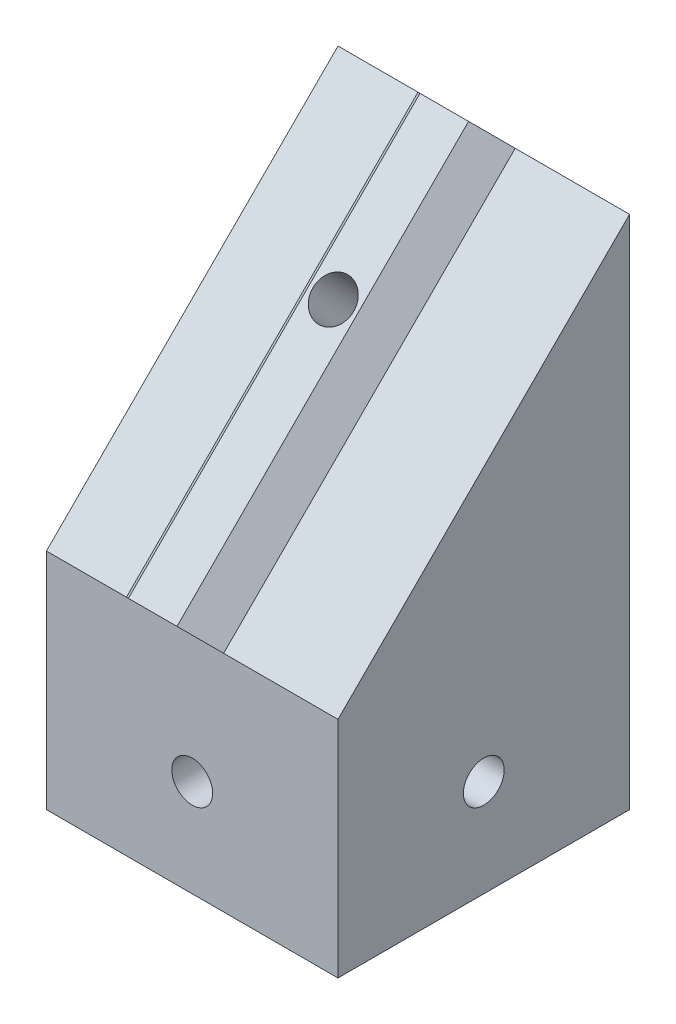
from build123d import *

# Parameters (mm, degrees)
SKETCH1_W           = 30
SKETCH1_H           = 30
SKETCH1_W_2         = 20
SKETCH1_H_2         = 20
BOSS_EXTRUDE1_DEPTH = 20
SKETCH2_W           = 4.711017494
SKETCH2_H           = 2
SKETCH2_W_2         = 2
SKETCH2_H_2         = 4.711017494
BOSS_EXTRUDE2_DEPTH = 20
SKETCH3_R           = 2.1
CUT_EXTRUDE1_DEPTH  = 31
SKETCH4_R           = 2.1
CUT_EXTRUDE2_DEPTH  = 31
BOSS_EXTRUDE3_DEPTH = 30
SKETCH8_W           = 4.711017494
SKETCH8_H           = 2.5
BOSS_EXTRUDE4_DEPTH = 42.42640687
SKETCH9_R           = 2.1
CUT_EXTRUDE3_DEPTH  = 44.261940705


with BuildPart() as part:
    # Sketch1 → Boss-Extrude1 (new body)
    with BuildSketch(Plane(origin=(0, 0, 0), x_dir=(1, 0, 0), z_dir=(0, 1, 0))):
        Rectangle(SKETCH1_W, SKETCH1_H)
        Rectangle(SKETCH1_W_2, SKETCH1_H_2, mode=Mode.SUBTRACT)
    extrude(amount=BOSS_EXTRUDE1_DEPTH)


with BuildPart() as body_2:
    # Sketch2 → Boss-Extrude2 (new body)
    with BuildSketch(Plane(origin=(0, 20, 0), x_dir=(1, 0, 0), z_dir=(0, 1, 0))):
        Polygon((2.336539675, 4), (-2.663460325, 4), (-4.950152781, 8), (5.049847219, 8), align=None)
        with Locations((0, 9)):
            Rectangle(SKETCH2_W, SKETCH2_H)
        Polygon((-4, 2.336539675), (-4, -2.663460325), (-8, -4.950152781), (-8, 5.049847219), align=None)
        Polygon((-2.336539675, -4), (2.663460325, -4), (4.950152781, -8), (-5.049847219, -8), align=None)
        with Locations((0, -9)):
            Rectangle(SKETCH2_W, SKETCH2_H)
        Polygon((4, 2.663460325), (4, -2.336539675), (8, -5.049847219), (8, -2.355508747), (8, 2.355508747), (8, 4.950152781), align=None)
        with Locations((9, 0)):
            Rectangle(SKETCH2_W_2, SKETCH2_H_2)
        with Locations((-9, 0)):
            Rectangle(SKETCH2_W_2, SKETCH2_H_2)
    extrude(amount=-BOSS_EXTRUDE2_DEPTH)


with BuildPart() as cut_extrude1_tool:
    # Sketch3 → Cut-Extrude1 (new body, through all)
    with BuildSketch(Plane.ZY.offset(15)):
        with Locations((0, 10)):
            Circle(SKETCH3_R)
    extrude(amount=-CUT_EXTRUDE1_DEPTH)


with BuildPart() as part_1:
    add(part.part)

    # Cut-Extrude1: cut by cut_extrude1_tool
    add(cut_extrude1_tool.part, mode=Mode.SUBTRACT)


with BuildPart() as body_2_1:
    add(body_2.part)

    # Cut-Extrude1: cut by cut_extrude1_tool
    add(cut_extrude1_tool.part, mode=Mode.SUBTRACT)


with BuildPart() as cut_extrude2_tool:
    # Sketch4 → Cut-Extrude2 (new body, through all)
    with BuildSketch(Plane(origin=(0, 0, -15), x_dir=(-1, 0, 0), z_dir=(0, 0, -1))):
        with Locations((0, 10)):
            Circle(SKETCH4_R)
    extrude(amount=-CUT_EXTRUDE2_DEPTH)


with BuildPart() as part_2:
    add(part_1.part)

    # Cut-Extrude2: cut by cut_extrude2_tool
    add(cut_extrude2_tool.part, mode=Mode.SUBTRACT)



with BuildPart() as body_2_2:
    add(body_2_1.part)

    # Cut-Extrude2: cut by cut_extrude2_tool
    add(cut_extrude2_tool.part, mode=Mode.SUBTRACT)


with BuildPart() as part_3:
    add(part_2.part)

    add(body_2_2.part)  # Boss-Extrude3 merges body 2
    # Sketch5 → Boss-Extrude3 (add)
    with BuildSketch(Plane(origin=(15, 0, 0), x_dir=(0, 0, -1), z_dir=(1, 0, 0))):
        Polygon((15, 53.049895295), (15, 50), (-15, 20), (-15, 23.049895295), align=None)
        Polygon((15, 50), (-15, 20), (15, 20), align=None)
    extrude(amount=-BOSS_EXTRUDE3_DEPTH)

    # Sketch8 → Boss-Extrude4 (add)
    with BuildSketch(Plane(origin=(0, 34.024947648, -34.024947648), x_dir=(1, 0, 0), z_dir=(0, -0.707106781, 0.707106781))):
        Polygon((2.5, 32.655338987), (-2.5, 32.655338987), (-4.999999998, 29.405338987), (-2.355508747, 29.405338987), (2.355508747, 29.405338987), (5.000000002, 29.405338987), align=None)
        with Locations((0, 28.155338987)):
            Rectangle(SKETCH8_W, SKETCH8_H)
    extrude(amount=BOSS_EXTRUDE4_DEPTH)

    # Sketch9 → Cut-Extrude3 (cut, through all)
    with BuildSketch(Plane(origin=(0, 23.090811639, 23.090811639), x_dir=(1, 0, 0), z_dir=(0, 0.707106781, 0.707106781))):
        with Locations((0, 31.96811151)):
            Circle(SKETCH9_R)
    extrude(amount=-CUT_EXTRUDE3_DEPTH, mode=Mode.SUBTRACT)


solid = part_3.part
